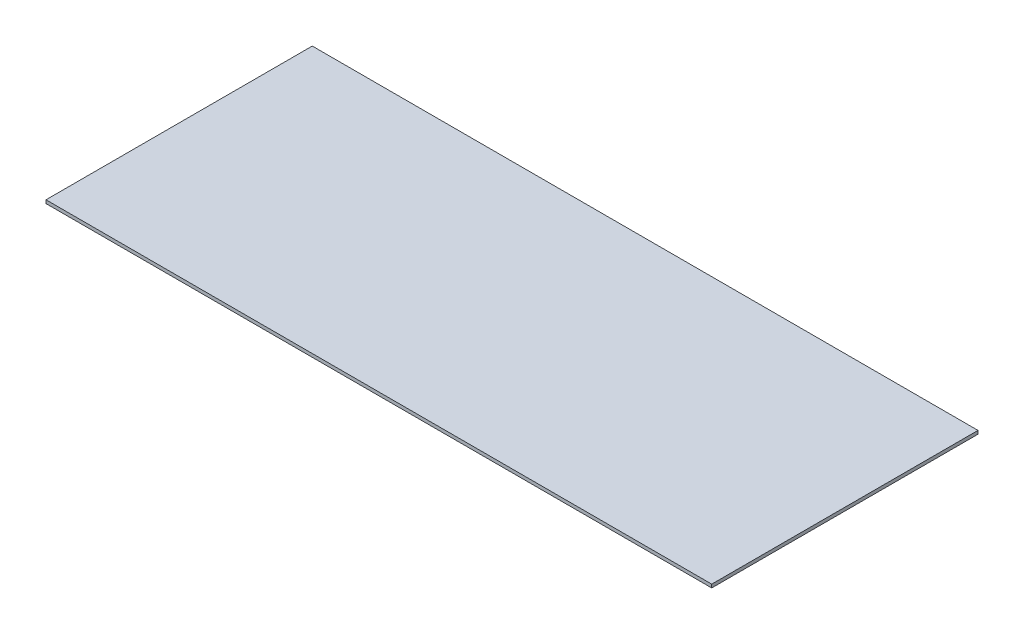
from build123d import *

# Parameters (mm, degrees)
SKETCH_1_W      = 200
SKETCH_1_H      = 80
EXTRUDE_1_DEPTH = 1


with BuildPart() as part:
    # 草图1 → 凸台-拉伸1 (new body)
    with BuildSketch(Plane(origin=(0, 0, 0), x_dir=(1, 0, 0), z_dir=(0, 1, 0))):
        Rectangle(SKETCH_1_W, SKETCH_1_H)
    extrude(amount=EXTRUDE_1_DEPTH)


solid = part.part
